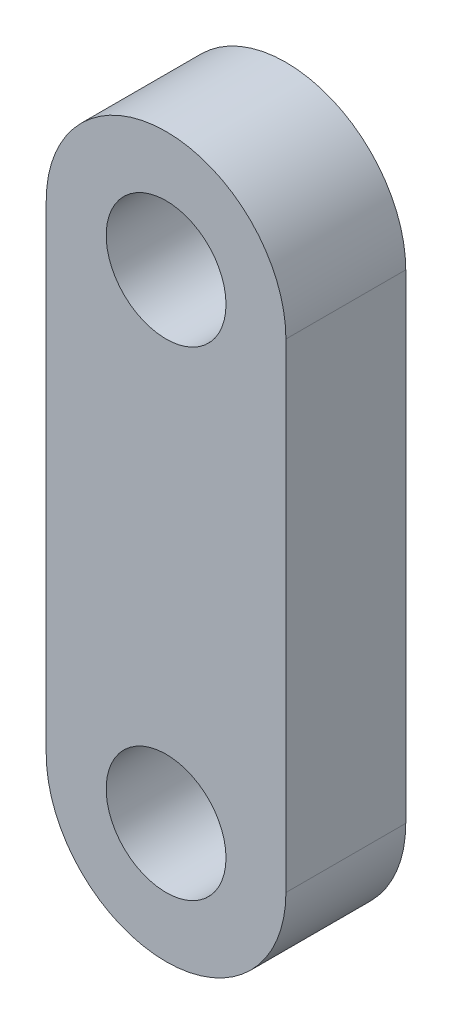
from build123d import *

# Parameters (mm, degrees)
SKETCH1_R           = 3.175
BOSS_EXTRUDE1_DEPTH = 6.35


with BuildPart() as part:
    # Sketch1 → Boss-Extrude1 (new body)
    with BuildSketch(Plane.XY):
        with BuildLine():
            Line((-6.35, 25.4), (-6.35, 0))
            ThreePointArc((-6.35, 0), (0, -6.35), (6.35, 0))
            Line((6.35, 0), (6.35, 25.4))
            ThreePointArc((6.35, 25.4), (0, 31.75), (-6.35, 25.4))
        make_face()
        Circle(SKETCH1_R, mode=Mode.SUBTRACT)
        with Locations((0, 25.4)):
            Circle(SKETCH1_R, mode=Mode.SUBTRACT)
    extrude(amount=BOSS_EXTRUDE1_DEPTH)


solid = part.part
